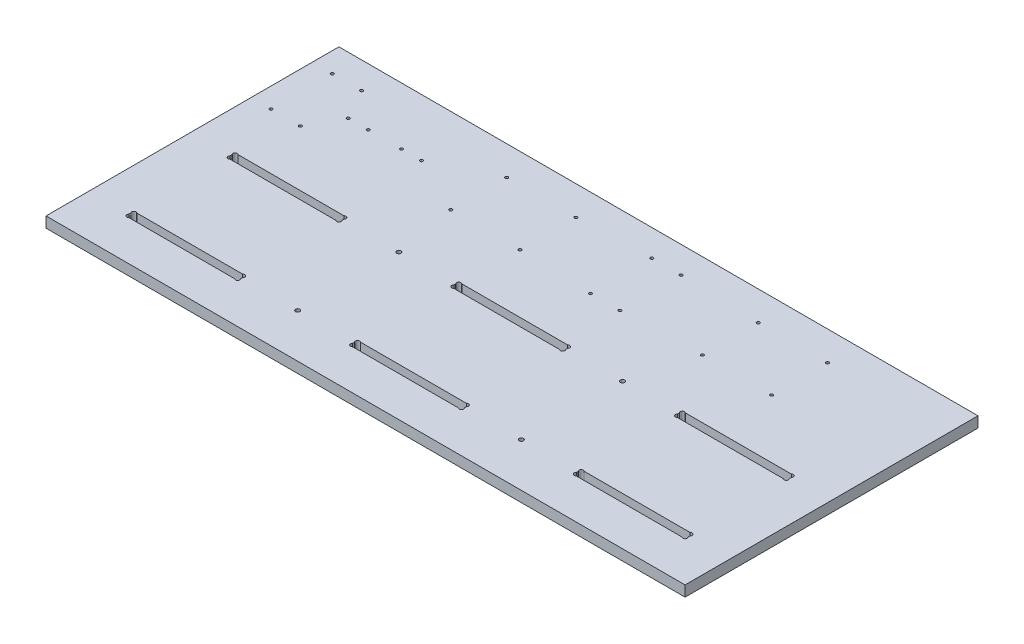
from build123d import *

# Parameters (mm, degrees)
ESQUISSE1_W        = 480
ESQUISSE1_H        = 220
ESQUISSE1_R        = 1.6
ESQUISSE1_R_2      = 1.1
BOSS_EXTRU_1_DEPTH = 8


with BuildPart() as part:
    # Esquisse1 → Boss.-Extru.1 (new body)
    with BuildSketch(Plane(origin=(0, 0, 0), x_dir=(1, 0, 0), z_dir=(0, 1, 0))):
        with Locations((250, 110)):
            Rectangle(ESQUISSE1_W, ESQUISSE1_H)
        with Locations(Location((166, 33, 0), (0, 0, 270))):  # turned: the seam where the file's is
            Circle(ESQUISSE1_R, mode=Mode.SUBTRACT)
        with Locations(Location((334, 33, 0), (0, 0, 90))):  # turned: the seam where the file's is
            Circle(ESQUISSE1_R, mode=Mode.SUBTRACT)
        with Locations(Location((334, 109, 0), (0, 0, 270))):  # turned: the seam where the file's is
            Circle(ESQUISSE1_R, mode=Mode.SUBTRACT)
        with Locations(Location((166, 109, 0), (0, 0, 90))):  # turned: the seam where the file's is
            Circle(ESQUISSE1_R, mode=Mode.SUBTRACT)
        with Locations(Location((158, 198, 0), (0, 0, 270))):  # turned: the seam where the file's is
            Circle(ESQUISSE1_R_2, mode=Mode.SUBTRACT)
        with Locations(Location((210, 198, 0), (0, 0, 90))):  # turned: the seam where the file's is
            Circle(ESQUISSE1_R_2, mode=Mode.SUBTRACT)
        with Locations(Location((210, 156, 0), (0, 0, 270))):  # turned: the seam where the file's is
            Circle(ESQUISSE1_R_2, mode=Mode.SUBTRACT)
        with Locations(Location((158, 156, 0), (0, 0, 90))):  # turned: the seam where the file's is
            Circle(ESQUISSE1_R_2, mode=Mode.SUBTRACT)
        with Locations(Location((60, 177, 0), (0, 0, 270))):  # turned: the seam where the file's is
            Circle(ESQUISSE1_R_2, mode=Mode.SUBTRACT)
        with Locations(Location((75, 177, 0), (0, 0, 270))):  # turned: the seam where the file's is
            Circle(ESQUISSE1_R_2, mode=Mode.SUBTRACT)
        with Locations(Location((100, 177, 0), (0, 0, 90))):  # turned: the seam where the file's is
            Circle(ESQUISSE1_R_2, mode=Mode.SUBTRACT)
        with Locations(Location((115, 177, 0), (0, 0, 90))):  # turned: the seam where the file's is
            Circle(ESQUISSE1_R_2, mode=Mode.SUBTRACT)
        with Locations(Location((25, 200, 0), (0, 0, 270))):  # turned: the seam where the file's is
            Circle(ESQUISSE1_R_2, mode=Mode.SUBTRACT)
        with Locations(Location((47, 200, 0), (0, 0, 270))):  # turned: the seam where the file's is
            Circle(ESQUISSE1_R_2, mode=Mode.SUBTRACT)
        with Locations(Location((47, 154, 0), (0, 0, 270))):  # turned: the seam where the file's is
            Circle(ESQUISSE1_R_2, mode=Mode.SUBTRACT)
        with Locations(Location((25, 154, 0), (0, 0, 270))):  # turned: the seam where the file's is
            Circle(ESQUISSE1_R_2, mode=Mode.SUBTRACT)
        with Locations(Location((287, 200, 0), (0, 0, 270))):  # turned: the seam where the file's is
            Circle(ESQUISSE1_R_2, mode=Mode.SUBTRACT)
        with Locations(Location((287, 154, 0), (0, 0, 270))):  # turned: the seam where the file's is
            Circle(ESQUISSE1_R_2, mode=Mode.SUBTRACT)
        with Locations(Location((265, 200, 0), (0, 0, 270))):  # turned: the seam where the file's is
            Circle(ESQUISSE1_R_2, mode=Mode.SUBTRACT)
        with Locations(Location((265, 154, 0), (0, 0, 270))):  # turned: the seam where the file's is
            Circle(ESQUISSE1_R_2, mode=Mode.SUBTRACT)
        with Locations(Location((399, 156, 0), (0, 0, 270))):  # turned: the seam where the file's is
            Circle(ESQUISSE1_R_2, mode=Mode.SUBTRACT)
        with Locations(Location((347, 198, 0), (0, 0, 270))):  # turned: the seam where the file's is
            Circle(ESQUISSE1_R_2, mode=Mode.SUBTRACT)
        with Locations(Location((347, 156, 0), (0, 0, 90))):  # turned: the seam where the file's is
            Circle(ESQUISSE1_R_2, mode=Mode.SUBTRACT)
        with Locations(Location((399, 198, 0), (0, 0, 90))):  # turned: the seam where the file's is
            Circle(ESQUISSE1_R_2, mode=Mode.SUBTRACT)
        with BuildLine():
            Line((40, 33.7372583), (40, 32.2627417))
            ThreePointArc((40, 32.2627417), (40, 30), (42.2627417, 30))
            Line((42.2627417, 30), (121.7372583, 30))
            ThreePointArc((121.7372583, 30), (124, 30), (124, 32.2627417))
            Line((124, 32.2627417), (124, 33.7372583))
            ThreePointArc((124, 33.7372583), (124, 36), (121.7372583, 36))
            Line((121.7372583, 36), (42.2627417, 36))
            ThreePointArc((42.2627417, 36), (40, 36), (40, 33.7372583))
        make_face(mode=Mode.SUBTRACT)
        with BuildLine():
            Line((378.2627417, 36), (457.7372583, 36))
            ThreePointArc((457.7372583, 36), (460, 36), (460, 33.7372583))
            Line((460, 33.7372583), (460, 32.2627417))
            ThreePointArc((460, 32.2627417), (460, 30), (457.7372583, 30))
            Line((457.7372583, 30), (378.2627417, 30))
            ThreePointArc((378.2627417, 30), (376, 30), (376, 32.2627417))
            Line((376, 32.2627417), (376, 33.7372583))
            ThreePointArc((376, 33.7372583), (376, 36), (378.2627417, 36))
        make_face(mode=Mode.SUBTRACT)
        with BuildLine():
            Line((208, 33.7372583), (208, 32.2627417))
            ThreePointArc((208, 32.2627417), (208, 30), (210.2627417, 30))
            Line((210.2627417, 30), (289.7372583, 30))
            ThreePointArc((289.7372583, 30), (292, 30), (292, 32.2627417))
            Line((292, 32.2627417), (292, 33.7372583))
            ThreePointArc((292, 33.7372583), (292, 36), (289.7372583, 36))
            Line((289.7372583, 36), (210.2627417, 36))
            ThreePointArc((210.2627417, 36), (208, 36), (208, 33.7372583))
        make_face(mode=Mode.SUBTRACT)
        with BuildLine():
            Line((289.7372583, 112), (210.2627417, 112))
            ThreePointArc((210.2627417, 112), (208, 112), (208, 109.7372583))
            Line((208, 109.7372583), (208, 108.2627417))
            ThreePointArc((208, 108.2627417), (208, 106), (210.2627417, 106))
            Line((210.2627417, 106), (289.7372583, 106))
            ThreePointArc((289.7372583, 106), (292, 106), (292, 108.2627417))
            Line((292, 108.2627417), (292, 109.7372583))
            ThreePointArc((292, 109.7372583), (292, 112), (289.7372583, 112))
        make_face(mode=Mode.SUBTRACT)
        with BuildLine():
            Line((460, 108.2627417), (460, 109.7372583))
            ThreePointArc((460, 109.7372583), (460, 112), (457.7372583, 112))
            Line((457.7372583, 112), (378.2627417, 112))
            ThreePointArc((378.2627417, 112), (376, 112), (376, 109.7372583))
            Line((376, 109.7372583), (376, 108.2627417))
            ThreePointArc((376, 108.2627417), (376, 106), (378.2627417, 106))
            Line((378.2627417, 106), (457.7372583, 106))
            ThreePointArc((457.7372583, 106), (460, 106), (460, 108.2627417))
        make_face(mode=Mode.SUBTRACT)
        with BuildLine():
            Line((121.7372583, 106), (42.2627417, 106))
            ThreePointArc((42.2627417, 106), (40, 106), (40, 108.2627417))
            Line((40, 108.2627417), (40, 109.7372583))
            ThreePointArc((40, 109.7372583), (40, 112), (42.2627417, 112))
            Line((42.2627417, 112), (121.7372583, 112))
            ThreePointArc((121.7372583, 112), (124, 112), (124, 109.7372583))
            Line((124, 109.7372583), (124, 108.2627417))
            ThreePointArc((124, 108.2627417), (124, 106), (121.7372583, 106))
        make_face(mode=Mode.SUBTRACT)
    extrude(amount=BOSS_EXTRU_1_DEPTH)


solid = part.part
